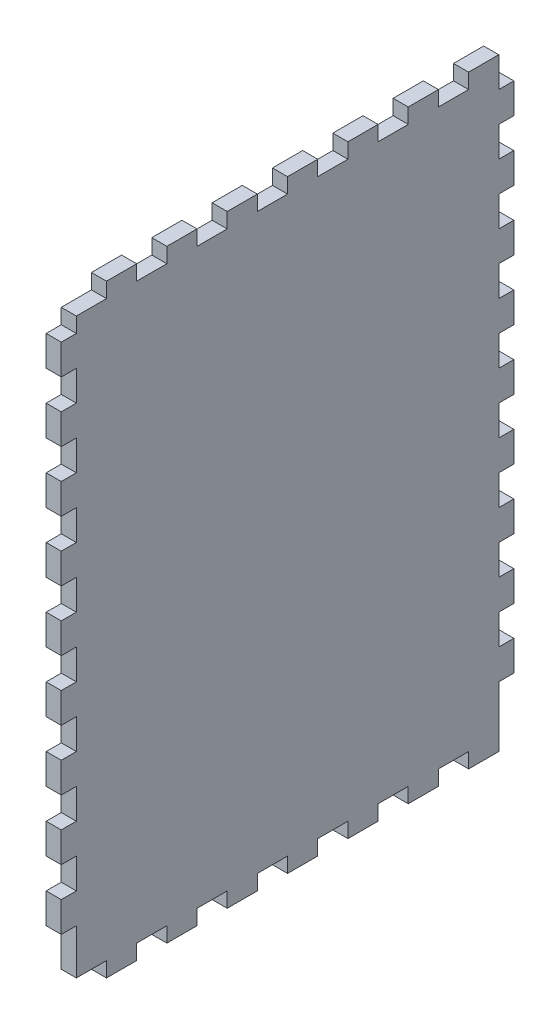
from build123d import *

# Parameters (mm, degrees)
SKETCH1_W               = 190.5
SKETCH1_H               = 254
BOSS_EXTRUDE1_DEPTH     = 6.35
SKETCH2_W               = 6.35
SKETCH2_H               = 12.7
CUT_EXTRUDE1_DEPTH      = 7.35
LPATTERN1_COUNT         = 9
LPATTERN1_PITCH         = 25.4
MIRROR1_COPY_1_SKETCH_W = 6.35
MIRROR1_COPY_1_SKETCH_H = 12.7
MIRROR1_COPY_1_DEPTH    = 7.35
MIRROR1_COPY_2_SKETCH_W = 6.35
MIRROR1_COPY_2_SKETCH_H = 12.7
MIRROR1_COPY_2_DEPTH    = 7.35
MIRROR1_COPY_3_SKETCH_W = 6.35
MIRROR1_COPY_3_SKETCH_H = 12.7
MIRROR1_COPY_3_DEPTH    = 7.35
MIRROR1_COPY_4_SKETCH_W = 6.35
MIRROR1_COPY_4_SKETCH_H = 12.7
MIRROR1_COPY_4_DEPTH    = 7.35
MIRROR1_COPY_5_SKETCH_W = 6.35
MIRROR1_COPY_5_SKETCH_H = 12.7
MIRROR1_COPY_5_DEPTH    = 7.35
MIRROR1_COPY_6_SKETCH_W = 6.35
MIRROR1_COPY_6_SKETCH_H = 12.7
MIRROR1_COPY_6_DEPTH    = 7.35
MIRROR1_COPY_7_SKETCH_W = 6.35
MIRROR1_COPY_7_SKETCH_H = 12.7
MIRROR1_COPY_7_DEPTH    = 7.35
MIRROR1_COPY_8_SKETCH_W = 6.35
MIRROR1_COPY_8_SKETCH_H = 12.7
MIRROR1_COPY_8_DEPTH    = 7.35
SKETCH3_W               = 12.7
SKETCH3_H               = 6.35
CUT_EXTRUDE2_DEPTH      = 7.35
LPATTERN2_COUNT         = 7
LPATTERN2_PITCH         = 25.4
MIRROR2_COPY_1_SKETCH_W = 12.7
MIRROR2_COPY_1_SKETCH_H = 6.35
MIRROR2_COPY_1_DEPTH    = 7.35
MIRROR2_COPY_2_SKETCH_W = 12.7
MIRROR2_COPY_2_SKETCH_H = 6.35
MIRROR2_COPY_2_DEPTH    = 7.35
MIRROR2_COPY_3_SKETCH_W = 12.7
MIRROR2_COPY_3_SKETCH_H = 6.35
MIRROR2_COPY_3_DEPTH    = 7.35
MIRROR2_COPY_4_SKETCH_W = 12.7
MIRROR2_COPY_4_SKETCH_H = 6.35
MIRROR2_COPY_4_DEPTH    = 7.35
MIRROR2_COPY_5_SKETCH_W = 12.7
MIRROR2_COPY_5_SKETCH_H = 6.35
MIRROR2_COPY_5_DEPTH    = 7.35
MIRROR2_COPY_6_SKETCH_W = 12.7
MIRROR2_COPY_6_SKETCH_H = 6.35
MIRROR2_COPY_6_DEPTH    = 7.35
SKETCH4_W               = 6.35
SKETCH4_H               = 25.4
CUT_EXTRUDE3_DEPTH      = 7.35


with BuildPart() as part:
    # Sketch1 → Boss-Extrude1 (new body)
    with BuildSketch(Plane(origin=(0, 0, 0), x_dir=(0, 0, -1), z_dir=(1, 0, 0))):
        Rectangle(SKETCH1_W, SKETCH1_H)
    extrude(amount=BOSS_EXTRUDE1_DEPTH)

    # Sketch2 → Cut-Extrude1 (cut, through all)
    with BuildSketch(Plane.ZY):
        with Locations((-92.075, -82.55)):
            Rectangle(SKETCH2_W, SKETCH2_H)
    cut_extrude1 = extrude(amount=-CUT_EXTRUDE1_DEPTH, mode=Mode.SUBTRACT)

    # LPattern1: Cut-Extrude1 ×9
    with Locations(*[(0, i * LPATTERN1_PITCH, 0) for i in range(1, LPATTERN1_COUNT)]):
        add(cut_extrude1, mode=Mode.SUBTRACT)

    # Mirror1: Cut-Extrude1 across plane
    add(cut_extrude1.mirror(Plane.XY), mode=Mode.SUBTRACT)

    # Mirror1 copy 1 sketch → Mirror1 copy 1 (cut, through all)
    with BuildSketch(Plane(origin=(0, 25.4, 0), x_dir=(0, 0, -1), z_dir=(-1, 0, 0))):
        with Locations((-92.075, 82.55)):
            Rectangle(MIRROR1_COPY_1_SKETCH_W, MIRROR1_COPY_1_SKETCH_H)
    extrude(amount=-MIRROR1_COPY_1_DEPTH, mode=Mode.SUBTRACT)

    # Mirror1 copy 2 sketch → Mirror1 copy 2 (cut, through all)
    with BuildSketch(Plane(origin=(0, 50.8, 0), x_dir=(0, 0, -1), z_dir=(-1, 0, 0))):
        with Locations((-92.075, 82.55)):
            Rectangle(MIRROR1_COPY_2_SKETCH_W, MIRROR1_COPY_2_SKETCH_H)
    extrude(amount=-MIRROR1_COPY_2_DEPTH, mode=Mode.SUBTRACT)

    # Mirror1 copy 3 sketch → Mirror1 copy 3 (cut, through all)
    with BuildSketch(Plane(origin=(0, 76.2, 0), x_dir=(0, 0, -1), z_dir=(-1, 0, 0))):
        with Locations((-92.075, 82.55)):
            Rectangle(MIRROR1_COPY_3_SKETCH_W, MIRROR1_COPY_3_SKETCH_H)
    extrude(amount=-MIRROR1_COPY_3_DEPTH, mode=Mode.SUBTRACT)

    # Mirror1 copy 4 sketch → Mirror1 copy 4 (cut, through all)
    with BuildSketch(Plane(origin=(0, 101.6, 0), x_dir=(0, 0, -1), z_dir=(-1, 0, 0))):
        with Locations((-92.075, 82.55)):
            Rectangle(MIRROR1_COPY_4_SKETCH_W, MIRROR1_COPY_4_SKETCH_H)
    extrude(amount=-MIRROR1_COPY_4_DEPTH, mode=Mode.SUBTRACT)

    # Mirror1 copy 5 sketch → Mirror1 copy 5 (cut, through all)
    with BuildSketch(Plane(origin=(0, 127, 0), x_dir=(0, 0, -1), z_dir=(-1, 0, 0))):
        with Locations((-92.075, 82.55)):
            Rectangle(MIRROR1_COPY_5_SKETCH_W, MIRROR1_COPY_5_SKETCH_H)
    extrude(amount=-MIRROR1_COPY_5_DEPTH, mode=Mode.SUBTRACT)

    # Mirror1 copy 6 sketch → Mirror1 copy 6 (cut, through all)
    with BuildSketch(Plane(origin=(0, 152.4, 0), x_dir=(0, 0, -1), z_dir=(-1, 0, 0))):
        with Locations((-92.075, 82.55)):
            Rectangle(MIRROR1_COPY_6_SKETCH_W, MIRROR1_COPY_6_SKETCH_H)
    extrude(amount=-MIRROR1_COPY_6_DEPTH, mode=Mode.SUBTRACT)

    # Mirror1 copy 7 sketch → Mirror1 copy 7 (cut, through all)
    with BuildSketch(Plane(origin=(0, 177.8, 0), x_dir=(0, 0, -1), z_dir=(-1, 0, 0))):
        with Locations((-92.075, 82.55)):
            Rectangle(MIRROR1_COPY_7_SKETCH_W, MIRROR1_COPY_7_SKETCH_H)
    extrude(amount=-MIRROR1_COPY_7_DEPTH, mode=Mode.SUBTRACT)

    # Mirror1 copy 8 sketch → Mirror1 copy 8 (cut, through all)
    with BuildSketch(Plane(origin=(0, 203.2, 0), x_dir=(0, 0, -1), z_dir=(-1, 0, 0))):
        with Locations((-92.075, 82.55)):
            Rectangle(MIRROR1_COPY_8_SKETCH_W, MIRROR1_COPY_8_SKETCH_H)
    extrude(amount=-MIRROR1_COPY_8_DEPTH, mode=Mode.SUBTRACT)

    # Sketch3 → Cut-Extrude2 (cut, through all)
    with BuildSketch(Plane.ZY):
        with Locations((-69.85, -123.825)):
            Rectangle(SKETCH3_W, SKETCH3_H)
    cut_extrude2 = extrude(amount=-CUT_EXTRUDE2_DEPTH, mode=Mode.SUBTRACT)

    # LPattern2: Cut-Extrude2 ×7
    with Locations(*[(0, 0, i * LPATTERN2_PITCH) for i in range(1, LPATTERN2_COUNT)]):
        add(cut_extrude2, mode=Mode.SUBTRACT)

    # Mirror2: Cut-Extrude2 across plane
    add(cut_extrude2.mirror(Plane.ZX), mode=Mode.SUBTRACT)

    # Mirror2 copy 1 sketch → Mirror2 copy 1 (cut, through all)
    with BuildSketch(Plane(origin=(0, 0, 25.4), x_dir=(0, 0, 1), z_dir=(-1, 0, 0))):
        with Locations((-69.85, 123.825)):
            Rectangle(MIRROR2_COPY_1_SKETCH_W, MIRROR2_COPY_1_SKETCH_H)
    extrude(amount=-MIRROR2_COPY_1_DEPTH, mode=Mode.SUBTRACT)

    # Mirror2 copy 2 sketch → Mirror2 copy 2 (cut, through all)
    with BuildSketch(Plane(origin=(0, 0, 50.8), x_dir=(0, 0, 1), z_dir=(-1, 0, 0))):
        with Locations((-69.85, 123.825)):
            Rectangle(MIRROR2_COPY_2_SKETCH_W, MIRROR2_COPY_2_SKETCH_H)
    extrude(amount=-MIRROR2_COPY_2_DEPTH, mode=Mode.SUBTRACT)

    # Mirror2 copy 3 sketch → Mirror2 copy 3 (cut, through all)
    with BuildSketch(Plane(origin=(0, 0, 76.2), x_dir=(0, 0, 1), z_dir=(-1, 0, 0))):
        with Locations((-69.85, 123.825)):
            Rectangle(MIRROR2_COPY_3_SKETCH_W, MIRROR2_COPY_3_SKETCH_H)
    extrude(amount=-MIRROR2_COPY_3_DEPTH, mode=Mode.SUBTRACT)

    # Mirror2 copy 4 sketch → Mirror2 copy 4 (cut, through all)
    with BuildSketch(Plane(origin=(0, 0, 101.6), x_dir=(0, 0, 1), z_dir=(-1, 0, 0))):
        with Locations((-69.85, 123.825)):
            Rectangle(MIRROR2_COPY_4_SKETCH_W, MIRROR2_COPY_4_SKETCH_H)
    extrude(amount=-MIRROR2_COPY_4_DEPTH, mode=Mode.SUBTRACT)

    # Mirror2 copy 5 sketch → Mirror2 copy 5 (cut, through all)
    with BuildSketch(Plane(origin=(0, 0, 127), x_dir=(0, 0, 1), z_dir=(-1, 0, 0))):
        with Locations((-69.85, 123.825)):
            Rectangle(MIRROR2_COPY_5_SKETCH_W, MIRROR2_COPY_5_SKETCH_H)
    extrude(amount=-MIRROR2_COPY_5_DEPTH, mode=Mode.SUBTRACT)

    # Mirror2 copy 6 sketch → Mirror2 copy 6 (cut, through all)
    with BuildSketch(Plane(origin=(0, 0, 152.4), x_dir=(0, 0, 1), z_dir=(-1, 0, 0))):
        with Locations((-69.85, 123.825)):
            Rectangle(MIRROR2_COPY_6_SKETCH_W, MIRROR2_COPY_6_SKETCH_H)
    extrude(amount=-MIRROR2_COPY_6_DEPTH, mode=Mode.SUBTRACT)

    # Sketch4 → Cut-Extrude3 (cut, through all)
    with BuildSketch(Plane.ZY):
        with Locations((-92.075, -114.3)):
            Rectangle(SKETCH4_W, SKETCH4_H)
    cut_extrude3 = extrude(amount=-CUT_EXTRUDE3_DEPTH, mode=Mode.SUBTRACT)

    # Mirror3: Cut-Extrude3 across plane
    add(cut_extrude3.mirror(Plane.XY), mode=Mode.SUBTRACT)


solid = part.part
